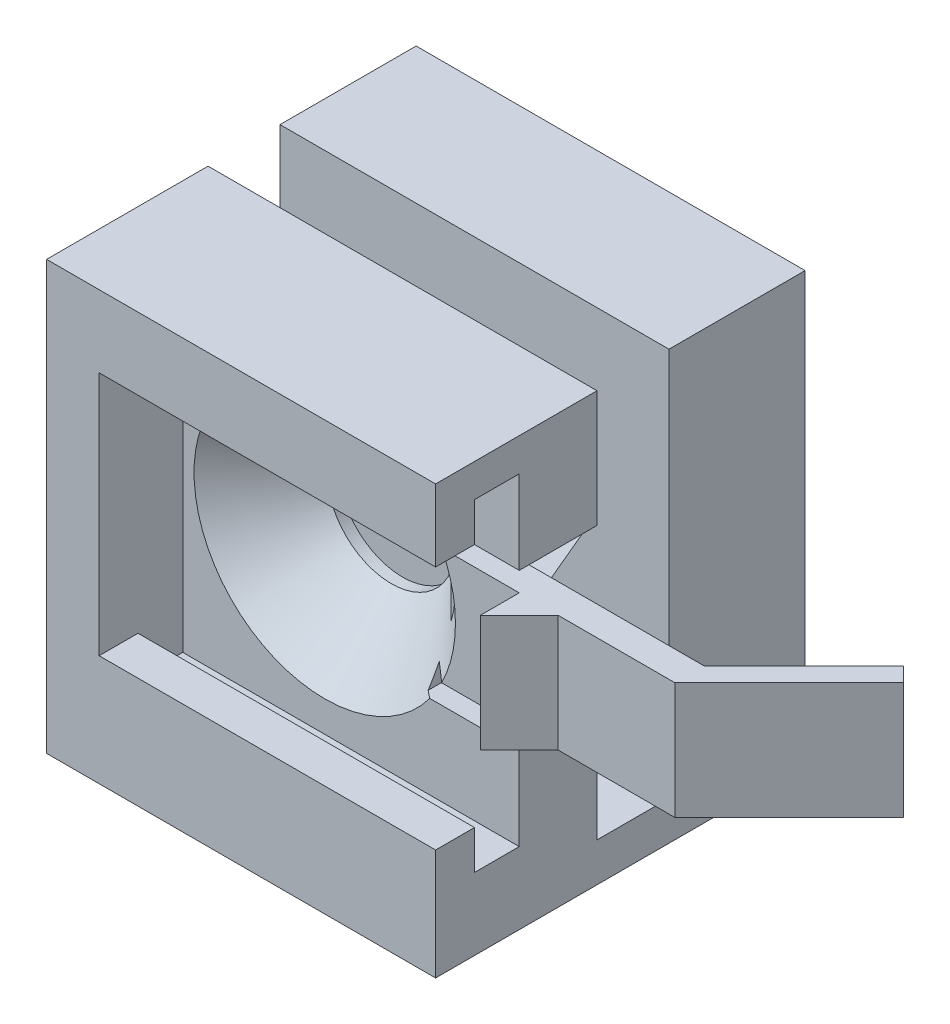
from build123d import *

# Parameters (mm, degrees)
CROQUIS1_W               = 20
CROQUIS1_H               = 20
CROQUIS1_R               = 3.1
SALIENTE_EXTRUIR1_DEPTH  = 4
SALIENTE_EXTRUIR2_DEPTH  = 2.3
SALIENTE_EXTRUIR4_DEPTH  = 2
SALIENTE_EXTRUIR5_DEPTH  = 4
SALIENTE_EXTRUIR6_START  = -6
SALIENTE_EXTRUIR6_DEPTH  = 6
CROQUIS10_W              = 5
CROQUIS10_H              = 1
CORTAR_EXTRUIR2_DEPTH    = 4
CORTAR_EXTRUIR3_START    = -13
CROQUIS11_W              = 2.5
CROQUIS11_H              = 6
CORTAR_EXTRUIR3_DEPTH    = 13
SALIENTE_EXTRUIR7_START  = -6
SALIENTE_EXTRUIR7_DEPTH  = 6
CROQUIS14_W              = 20
CROQUIS14_H              = 19
SALIENTE_EXTRUIR8_DEPTH  = 2
CROQUIS15_W              = 20
CROQUIS15_H              = 7
SALIENTE_EXTRUIR9_DEPTH  = 20
CORTAR_EXTRUIR4_DEPTH    = 5
CROQUIS17_R              = 3.3
CORTAR_EXTRUIR5_DEPTH    = 2
SALIENTE_EXTRUIR10_START = -6
SALIENTE_EXTRUIR10_DEPTH = 6


with BuildPart() as part:
    # Croquis1 → Saliente-Extruir1 (new body)
    with BuildSketch(Plane.XY):
        Rectangle(CROQUIS1_W, CROQUIS1_H)
        Circle(CROQUIS1_R, mode=Mode.SUBTRACT)
    extrude(amount=SALIENTE_EXTRUIR1_DEPTH)

    # Croquis3 → Saliente-Extruir2 (add)
    with BuildSketch(Plane.XY.offset(4)):
        Polygon((10, 10), (-10, 10), (-10, -10), (10, -10), (10, -8.3), (-7.3, -8.3), (-7.3, 8.3), (10, 8.3), align=None)
    extrude(amount=SALIENTE_EXTRUIR2_DEPTH)

    # Croquis6 → Saliente-Extruir4 (add)
    with BuildSketch(Plane.XY.offset(6.3)):
        Polygon((10, 10), (10, 6.3), (-7.3, 6.3), (-7.3, -6.3), (10, -6.3), (10, -10), (-10, -10), (-10, 10), align=None)
    extrude(amount=SALIENTE_EXTRUIR4_DEPTH)

    # Croquis7 → Saliente-Extruir5 (add)
    with BuildSketch(Plane.XY.offset(4)):
        Polygon((10, 0), (10, 3), (18, 3), (18, 0), (18, -3), (10, -3), align=None)
    extrude(amount=-SALIENTE_EXTRUIR5_DEPTH)

    # Croquis9 → Saliente-Extruir6 (add)
    with BuildSketch(Plane.XZ.offset(3).offset(SALIENTE_EXTRUIR6_START)):
        Polygon((12, 4), (10, 6), (10, 4), align=None)
    extrude(amount=SALIENTE_EXTRUIR6_DEPTH)

    # Croquis10 → Cortar-Extruir2 (cut)
    with BuildSketch(Plane.XY.offset(4)):
        with Locations((7.5, 3.5)):
            Rectangle(CROQUIS10_W, CROQUIS10_H)
        with Locations((7.5, -3.5)):
            Rectangle(CROQUIS10_W, CROQUIS10_H)
    extrude(amount=-CORTAR_EXTRUIR2_DEPTH, mode=Mode.SUBTRACT)

    # Croquis11 → Cortar-Extruir3 (cut)
    with BuildSketch(Plane(origin=(18, 0, 0), x_dir=(0, 0, -1), z_dir=(1, 0, 0)).offset(CORTAR_EXTRUIR3_START)):
        with Locations((-1.25, 0)):
            Rectangle(CROQUIS11_W, CROQUIS11_H)
    extrude(amount=CORTAR_EXTRUIR3_DEPTH, mode=Mode.SUBTRACT)

    # Croquis12 → Saliente-Extruir7 (add)
    with BuildSketch(Plane(origin=(0, 3, 0), x_dir=(1, 0, 0), z_dir=(0, 1, 0)).offset(SALIENTE_EXTRUIR7_START)):
        Polygon((18, -2.5), (23.125934171, 2.625934171), (23.875934171, 1.875934171), (18, -4), align=None)
    extrude(amount=SALIENTE_EXTRUIR7_DEPTH)

    # Croquis13 → Refrentado para tornillo tapón con cabeza plana de clavija de M61 (revolve, cut)
    with BuildSketch(Plane(origin=(0, 0, 4), x_dir=(0, -1, 0), z_dir=(1, 0, 0))):
        Polygon((0, 0), (0, 6.625934171), (3.3, 6.625934171), (3.3, 3.42), (6.72, 0), align=None)
    revolve(axis=Axis((0, 0, 10.35), (0, 0, -1)), mode=Mode.SUBTRACT)

    # Croquis14 → Saliente-Extruir8 (add)
    with BuildSketch(Plane.XZ.offset(10)):
        with Locations((0, -1.2)):
            Rectangle(CROQUIS14_W, CROQUIS14_H)
    extrude(amount=SALIENTE_EXTRUIR8_DEPTH)

    # Croquis15 → Saliente-Extruir9 (add)
    with BuildSketch(Plane(origin=(0, -10, 0), x_dir=(1, 0, 0), z_dir=(0, 1, 0))):
        with Locations((0, 7.2)):
            Rectangle(CROQUIS15_W, CROQUIS15_H)
    extrude(amount=SALIENTE_EXTRUIR9_DEPTH)

    # Croquis16 → Cortar-Extruir4 (cut)
    with BuildSketch(Plane.XY.offset(-3.7)):
        Polygon((5.802370205, 0), (2.901185103, 5.025), (-2.901185103, 5.025), (-5.802370205, 0), (-2.901185103, -5.025), (2.901185103, -5.025), align=None)
    extrude(amount=-CORTAR_EXTRUIR4_DEPTH, mode=Mode.SUBTRACT)

    # Croquis17 → Cortar-Extruir5 (cut)
    with BuildSketch(Plane.XY.offset(-8.7)):
        Circle(CROQUIS17_R)
    extrude(amount=-CORTAR_EXTRUIR5_DEPTH, mode=Mode.SUBTRACT)

    # Croquis19 → Saliente-Extruir10 (add)
    with BuildSketch(Plane.XZ.offset(3).offset(SALIENTE_EXTRUIR10_START)):
        Polygon((5, 2.5), (7, 2.5), (5, 0), align=None)
    extrude(amount=SALIENTE_EXTRUIR10_DEPTH)


solid = part.part
